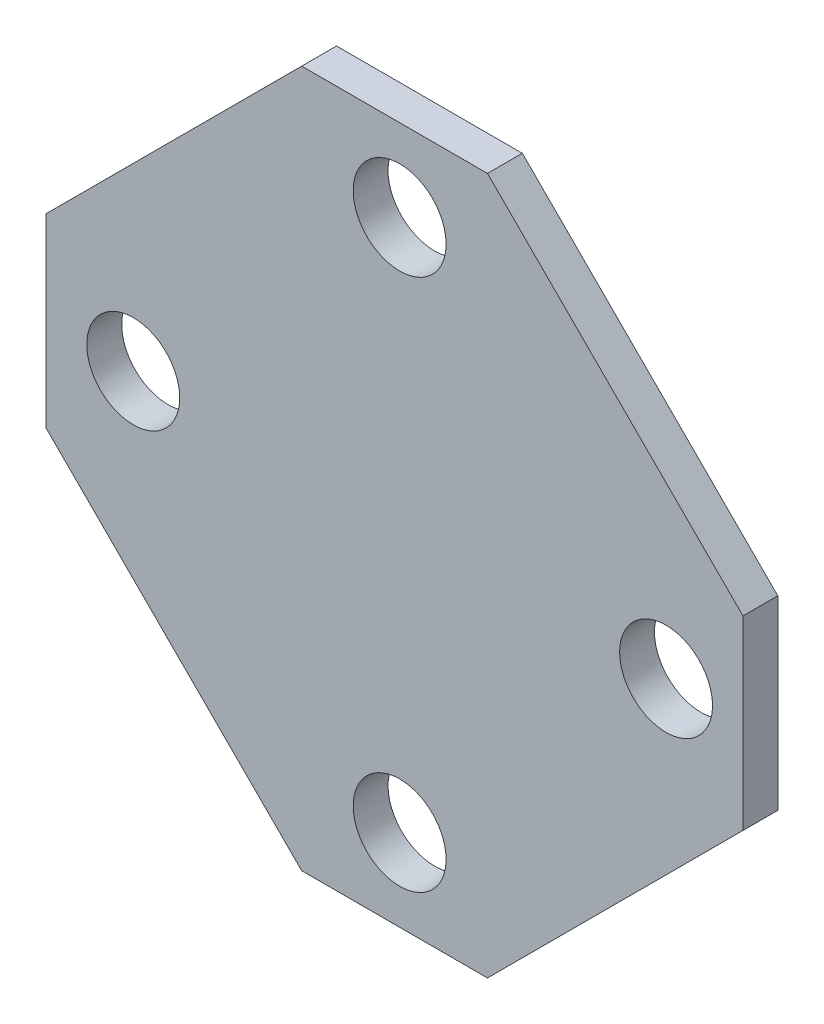
from build123d import *

# Parameters (mm, degrees)
BOSS_EXTRUDE2_DEPTH = 3
SKETCH1_3_R         = 4
CUT_EXTRUDE1_DEPTH  = 4
CIRPATTERN4_COUNT   = 4


with BuildPart() as part:
    # Sketch1 → Boss-Extrude2 (new body)
    with BuildSketch(Plane.XY):
        Polygon((-8, 30), (-30, 8), (-30, -8), (-8, -30), (8, -30), (30, -8), (30, 8), (8, 30), align=None)
    extrude(amount=BOSS_EXTRUDE2_DEPTH)

    # Sketch1_3 → Cut-Extrude1 (cut, through all)
    with BuildSketch(Plane.XY):
        with Locations((-22.5, 0)):
            Circle(SKETCH1_3_R)
    cut_extrude1 = extrude(amount=CUT_EXTRUDE1_DEPTH, mode=Mode.SUBTRACT)

    # CirPattern4: Cut-Extrude1 ×4 about axis
    cirpattern4_axis = Axis((0.438067256, 0, 0), (0, 0, 1))
    for i in range(1, CIRPATTERN4_COUNT):
        add(cut_extrude1.rotate(cirpattern4_axis, i * 360 / CIRPATTERN4_COUNT), mode=Mode.SUBTRACT)


solid = part.part
